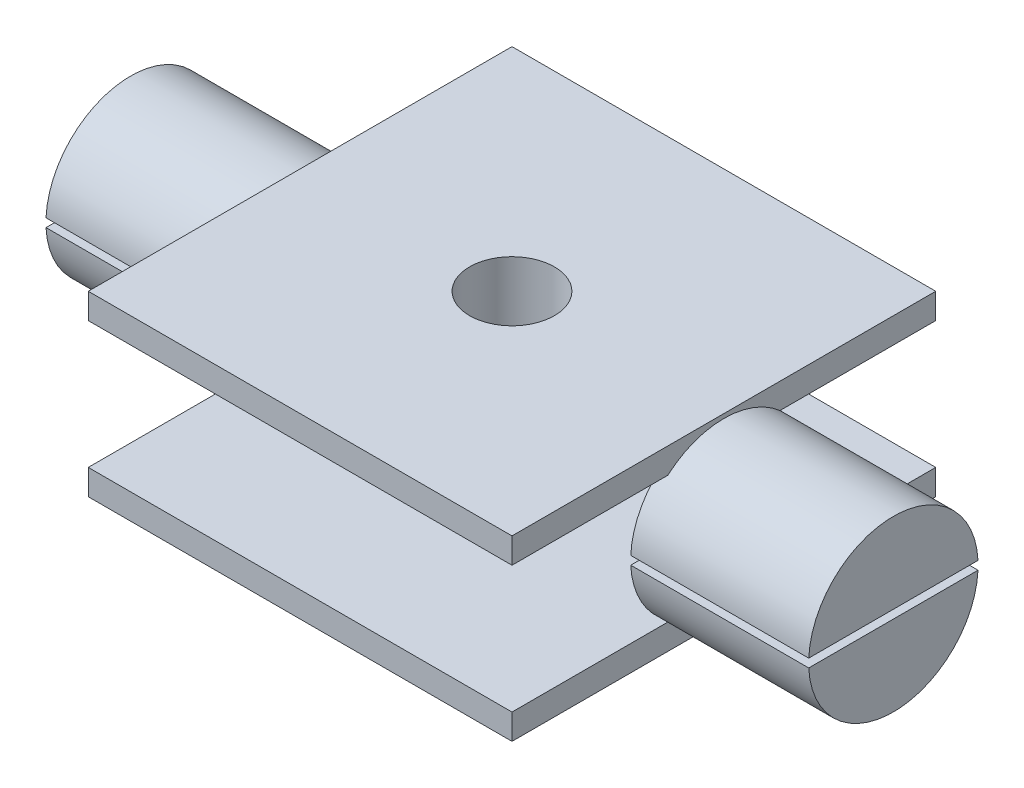
from build123d import *

# Parameters (mm, degrees)
SKETCH1_R                = 10
BOSS_EXTRUDE1_DEPTH      = 15
SKETCH3_W                = 50
SKETCH3_H                = 50
BOSS_EXTRUDE2_DEPTH      = 3
SKETCH5_W                = 50
SKETCH5_H                = 50
BOSS_EXTRUDE4_DEPTH      = 3
SKETCH7_R                = 10
BOSS_EXTRUDE5_DEPTH      = 20
BOSS_EXTRUDE5_DEPTH_BACK = 1
SKETCH8_R                = 10
BOSS_EXTRUDE6_DEPTH      = 20
BOSS_EXTRUDE6_DEPTH_BACK = 1
SKETCH9_W                = 28.965508976
SKETCH9_H                = 1
CUT_EXTRUDE2_DEPTH       = 21
SKETCH10_W               = 34.685430092
SKETCH10_H               = 1
CUT_EXTRUDE3_DEPTH       = 21
SKETCH6_R                = 5
CUT_EXTRUDE4_DEPTH       = 56.596762496
CUT_EXTRUDE5_START       = -2
SKETCH11_R               = 8
CUT_EXTRUDE5_DEPTH       = 17


with BuildPart() as part:
    # Sketch1 → Boss-Extrude1 (new body)
    with BuildSketch(Plane(origin=(0, 0, 0), x_dir=(1, 0, 0), z_dir=(0, 1, 0))):
        with Locations(Location((0, 0, 0), (0, 0, 270))):
            Circle(SKETCH1_R)
    extrude(amount=BOSS_EXTRUDE1_DEPTH)

    # Sketch3 → Boss-Extrude2 (add)
    with BuildSketch(Plane.XZ):
        Rectangle(SKETCH3_W, SKETCH3_H)
    extrude(amount=BOSS_EXTRUDE2_DEPTH)

    # Sketch5 → Boss-Extrude4 (add)
    with BuildSketch(Plane(origin=(0, 15, 0), x_dir=(1, 0, 0), z_dir=(0, 1, 0))):
        Rectangle(SKETCH5_W, SKETCH5_H)
    extrude(amount=BOSS_EXTRUDE4_DEPTH)

    # Sketch7 → Boss-Extrude5 (add, two sides)
    with BuildSketch(Plane.ZY.offset(25)) as boss_extrude5_sk:
        with Locations((0, 7.5)):
            Circle(SKETCH7_R)
    extrude(amount=BOSS_EXTRUDE5_DEPTH)
    extrude(boss_extrude5_sk.sketch, amount=-BOSS_EXTRUDE5_DEPTH_BACK)

    # Sketch8 → Boss-Extrude6 (add, two sides)
    with BuildSketch(Plane(origin=(25, 0, 0), x_dir=(0, 0, -1), z_dir=(1, 0, 0))) as boss_extrude6_sk:
        with Locations(Location((0, 7.5, 0), (0, 0, 180))):
            Circle(SKETCH8_R)
    extrude(amount=BOSS_EXTRUDE6_DEPTH)
    extrude(boss_extrude6_sk.sketch, amount=-BOSS_EXTRUDE6_DEPTH_BACK)

    # Sketch9 → Cut-Extrude2 (cut)
    with BuildSketch(Plane.ZY.offset(45)):
        with Locations((0, 7.5)):
            Rectangle(SKETCH9_W, SKETCH9_H)
    extrude(amount=-CUT_EXTRUDE2_DEPTH, mode=Mode.SUBTRACT)

    # Sketch10 → Cut-Extrude3 (cut)
    with BuildSketch(Plane(origin=(45, 0, 0), x_dir=(0, 0, -1), z_dir=(1, 0, 0))):
        with Locations((0, 7.5)):
            Rectangle(SKETCH10_W, SKETCH10_H)
    extrude(amount=-CUT_EXTRUDE3_DEPTH, mode=Mode.SUBTRACT)

    # Sketch6 → Cut-Extrude4 (cut, through all)
    with BuildSketch(Plane(origin=(0, 18, 0), x_dir=(1, 0, 0), z_dir=(0, 1, 0))):
        with Locations(Location((0, 0, 0), (0, 0, 270))):
            Circle(SKETCH6_R)
    extrude(amount=-CUT_EXTRUDE4_DEPTH, mode=Mode.SUBTRACT)

    # Sketch11 → Cut-Extrude5 (cut)
    with BuildSketch(Plane.ZY.offset(45).offset(CUT_EXTRUDE5_START)):
        with Locations((0, 7.5)):
            Circle(SKETCH11_R)
    extrude(amount=-CUT_EXTRUDE5_DEPTH, mode=Mode.SUBTRACT)

    # SurfaceCut1
    split(bisect_by=Plane(origin=(0, 0, 0), x_dir=(0, 0, -1), z_dir=(1, 0, 0)), keep=Keep.BOTTOM)

    # Mirror2: part across plane


with BuildPart() as part_1:
    add(part.part)
    add(part.part.mirror(Plane(origin=(0, 0, 0), x_dir=(0, 0, 1), z_dir=(1, 0, 0))))


solid = part_1.part
